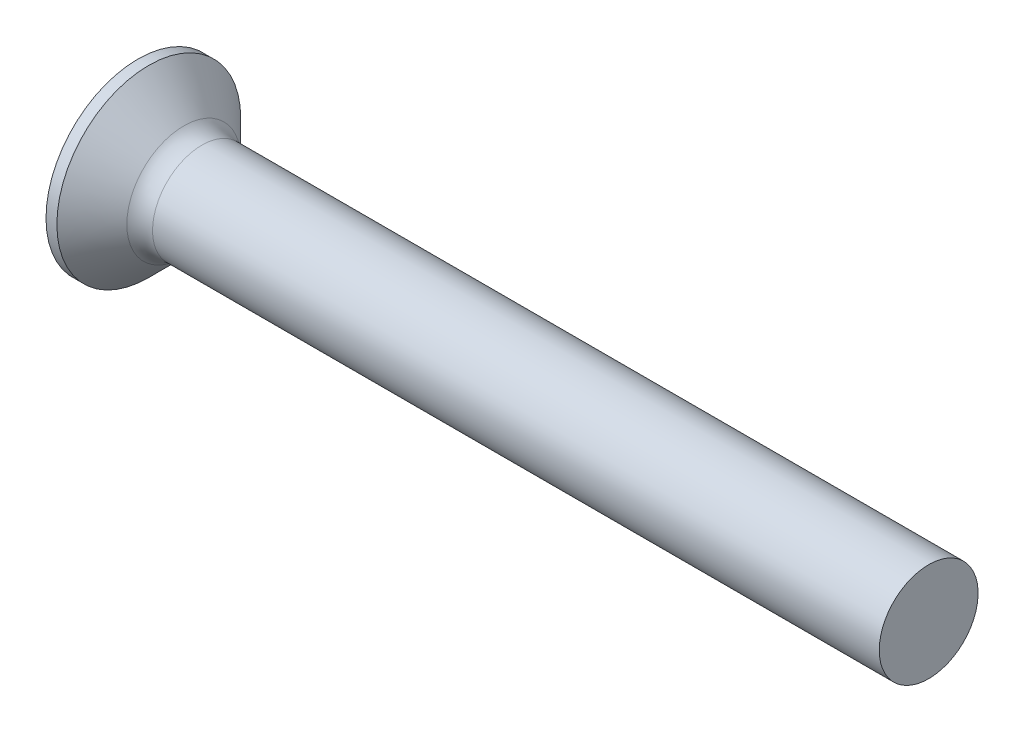
from build123d import *

# Parameters (mm, degrees)
FILLET1_R    = 1.3
SKETCH3_W    = 1.03
SKETCH3_H    = 4.9
SKETCH4_W    = 1.03
SKETCH4_H    = 1.858652296
RECPAT_COUNT = 2
RECPAT_ANGLE = 90


with BuildPart() as part:
    # BodySke → Base-Revolve (revolve)
    with BuildSketch(Plane.XY):
        Polygon((0, 0), (0, 4.65), (0.55, 4.65), (2.7, 2.5), (40, 2.5), (40, 0), align=None)
    revolve(axis=Axis((-6.35, 0, 0), (1, 0, 0)))

    # Fillet1
    fillet1_edges = [part.edges().sort_by_distance(p)[0] for p in [
        (2.7, -2.5, 0),
    ]]
    fillet(fillet1_edges, radius=FILLET1_R)

    # Sketch3 → Recess section 0
    with BuildSketch(Plane.ZY):
        Rectangle(SKETCH3_W, SKETCH3_H)
    # Sketch4 → Recess section 1
    with BuildSketch(Plane.ZY.offset(-3.05)):
        Rectangle(SKETCH4_W, SKETCH4_H)
    recess = loft(mode=Mode.SUBTRACT)

    # RecPat: Recess ×2 about axis
    recpat_axis = Axis((0, 0, 0), (1, 0, 0))
    for i in range(1, RECPAT_COUNT):
        add(recess.rotate(recpat_axis, i * RECPAT_ANGLE / (RECPAT_COUNT - 1)), mode=Mode.SUBTRACT)

    # RecCorSke → RecessCore (revolve, cut)
    with BuildSketch(Plane.XY):
        Polygon((0, 0), (0, 1.064276776), (3.05, 0.851), (3.326506661, 0), align=None)
    revolve(axis=Axis((-3.175, 0, 0), (1, 0, 0)), mode=Mode.SUBTRACT)


solid = part.part
